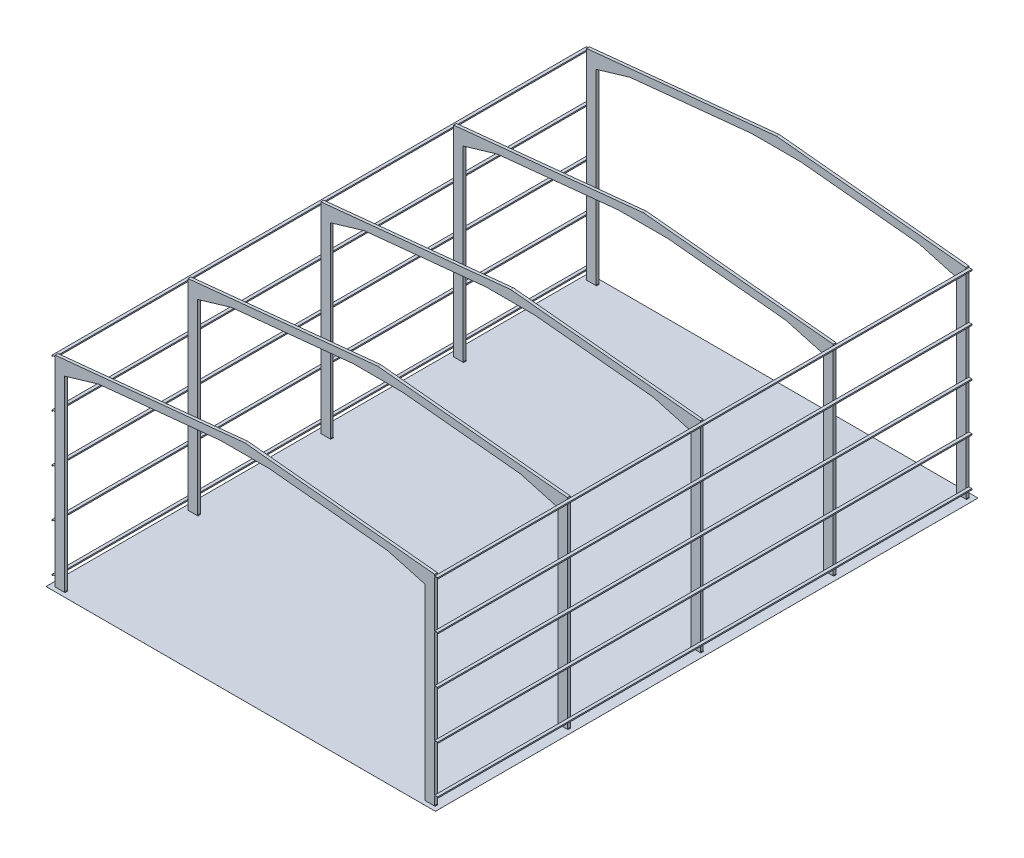
from build123d import *

# Parameters (mm, degrees)
EXTRUDE3_DEPTH       = 150
EXTRUDE4_DEPTH       = 28150
LPATTERN1_COUNT      = 5
LPATTERN1_PITCH      = 2500
MIRROR1_COPY_1_DEPTH = 28150
MIRROR1_COPY_2_DEPTH = 28150
MIRROR1_COPY_3_DEPTH = 28150
MIRROR1_COPY_4_DEPTH = 28150
LPATTERN2_COUNT      = 5
LPATTERN2_PITCH      = 7000
SKETCH57_W           = 20517.742297694
SKETCH57_H           = 28590
EXTRUDE5_DEPTH       = 1


with BuildPart() as part:
    # Sketch55 → Extrude3 (new body)
    with BuildSketch(Plane.XY):
        Polygon((128234.445628029, -90476.254441919), (128234.445628029, -80629.954441919), (130024.247115637, -80099.228646419), (136434.445628029, -79458.20879518), (137734.445628029, -79458.20879518), (139034.445628029, -79458.20879518), (145244.644140421, -80079.228646419), (147234.445628029, -80629.954441919), (147234.445628029, -90476.254441919), (147209.445628029, -90501.254441919), (147759.445628029, -90501.254441919), (147734.445628029, -90476.254441919), (147734.445628029, -79926.213770335), (137734.445628029, -78926.213770335), (127734.445628029, -79926.213770335), (127734.445628029, -90476.254441919), (127709.445628029, -90501.254441919), (128259.445628029, -90501.254441919), align=None)
    extrude3 = extrude(amount=EXTRUDE3_DEPTH)

    # Sketch56 → Extrude4 (add)
    with BuildSketch(Plane.XY):
        with BuildLine():
            Line((147891.623199959, -90066.254441919), (147894.445628029, -90066.254441919))
            Line((147894.445628029, -90066.254441919), (147894.445628029, -90001.254441919))
            Line((147894.445628029, -90001.254441919), (147734.445628029, -90001.254441919))
            Line((147734.445628029, -90001.254441919), (147734.445628029, -90066.254441919))
            Line((147734.445628029, -90066.254441919), (147737.268056099, -90066.254441919))
            ThreePointArc((147737.268056099, -90066.254441919), (147740.998854072, -90064.795623243), (147742.750540131, -90061.193040642))
            Line((147742.750540131, -90061.193040642), (147746.172614016, -90018.417117085))
            ThreePointArc((147746.172614016, -90018.417117085), (147749.516741947, -90011.539459393), (147756.63917444, -90008.754441919))
            Line((147756.63917444, -90008.754441919), (147814.445628029, -90008.754441919))
            Line((147814.445628029, -90008.754441919), (147872.252081618, -90008.754441919))
            ThreePointArc((147872.252081618, -90008.754441919), (147879.374514111, -90011.539459393), (147882.718642042, -90018.417117085))
            Line((147882.718642042, -90018.417117085), (147886.140715927, -90061.193040642))
            ThreePointArc((147886.140715927, -90061.193040642), (147887.892401986, -90064.795623243), (147891.623199959, -90066.254441919))
        make_face()
    extrude4 = extrude(amount=EXTRUDE4_DEPTH)

    # LPattern1: Extrude4 ×5
    with Locations(*[(0, i * LPATTERN1_PITCH, 0) for i in range(1, LPATTERN1_COUNT)]):
        add(extrude4)

    # Mirror1: Extrude4 across plane
    add(extrude4.mirror(Plane(origin=(137734.445628029, 0, 0), x_dir=(0, 0, 1), z_dir=(1, 0, 0))))

    # Mirror1 copy 1 sketch → Mirror1 copy 1 (add)
    with BuildSketch(Plane(origin=(275468.891256058, 2500, 0), x_dir=(-1, 0, 0), z_dir=(0, 0, 1))):
        with BuildLine():
            Line((147891.623199959, 90066.254441919), (147894.445628029, 90066.254441919))
            Line((147894.445628029, 90066.254441919), (147894.445628029, 90001.254441919))
            Line((147894.445628029, 90001.254441919), (147734.445628029, 90001.254441919))
            Line((147734.445628029, 90001.254441919), (147734.445628029, 90066.254441919))
            Line((147734.445628029, 90066.254441919), (147737.268056099, 90066.254441919))
            ThreePointArc((147737.268056099, 90066.254441919), (147740.998854072, 90064.795623243), (147742.750540131, 90061.193040642))
            Line((147742.750540131, 90061.193040642), (147746.172614016, 90018.417117085))
            ThreePointArc((147746.172614016, 90018.417117085), (147749.516741947, 90011.539459393), (147756.63917444, 90008.754441919))
            Line((147756.63917444, 90008.754441919), (147814.445628029, 90008.754441919))
            Line((147814.445628029, 90008.754441919), (147872.252081618, 90008.754441919))
            ThreePointArc((147872.252081618, 90008.754441919), (147879.374514111, 90011.539459393), (147882.718642042, 90018.417117085))
            Line((147882.718642042, 90018.417117085), (147886.140715927, 90061.193040642))
            ThreePointArc((147886.140715927, 90061.193040642), (147887.892401986, 90064.795623243), (147891.623199959, 90066.254441919))
        make_face()
    extrude(amount=MIRROR1_COPY_1_DEPTH)

    # Mirror1 copy 2 sketch → Mirror1 copy 2 (add)
    with BuildSketch(Plane(origin=(275468.891256058, 5000, 0), x_dir=(-1, 0, 0), z_dir=(0, 0, 1))):
        with BuildLine():
            Line((147891.623199959, 90066.254441919), (147894.445628029, 90066.254441919))
            Line((147894.445628029, 90066.254441919), (147894.445628029, 90001.254441919))
            Line((147894.445628029, 90001.254441919), (147734.445628029, 90001.254441919))
            Line((147734.445628029, 90001.254441919), (147734.445628029, 90066.254441919))
            Line((147734.445628029, 90066.254441919), (147737.268056099, 90066.254441919))
            ThreePointArc((147737.268056099, 90066.254441919), (147740.998854072, 90064.795623243), (147742.750540131, 90061.193040642))
            Line((147742.750540131, 90061.193040642), (147746.172614016, 90018.417117085))
            ThreePointArc((147746.172614016, 90018.417117085), (147749.516741947, 90011.539459393), (147756.63917444, 90008.754441919))
            Line((147756.63917444, 90008.754441919), (147814.445628029, 90008.754441919))
            Line((147814.445628029, 90008.754441919), (147872.252081618, 90008.754441919))
            ThreePointArc((147872.252081618, 90008.754441919), (147879.374514111, 90011.539459393), (147882.718642042, 90018.417117085))
            Line((147882.718642042, 90018.417117085), (147886.140715927, 90061.193040642))
            ThreePointArc((147886.140715927, 90061.193040642), (147887.892401986, 90064.795623243), (147891.623199959, 90066.254441919))
        make_face()
    extrude(amount=MIRROR1_COPY_2_DEPTH)

    # Mirror1 copy 3 sketch → Mirror1 copy 3 (add)
    with BuildSketch(Plane(origin=(275468.891256058, 7500, 0), x_dir=(-1, 0, 0), z_dir=(0, 0, 1))):
        with BuildLine():
            Line((147891.623199959, 90066.254441919), (147894.445628029, 90066.254441919))
            Line((147894.445628029, 90066.254441919), (147894.445628029, 90001.254441919))
            Line((147894.445628029, 90001.254441919), (147734.445628029, 90001.254441919))
            Line((147734.445628029, 90001.254441919), (147734.445628029, 90066.254441919))
            Line((147734.445628029, 90066.254441919), (147737.268056099, 90066.254441919))
            ThreePointArc((147737.268056099, 90066.254441919), (147740.998854072, 90064.795623243), (147742.750540131, 90061.193040642))
            Line((147742.750540131, 90061.193040642), (147746.172614016, 90018.417117085))
            ThreePointArc((147746.172614016, 90018.417117085), (147749.516741947, 90011.539459393), (147756.63917444, 90008.754441919))
            Line((147756.63917444, 90008.754441919), (147814.445628029, 90008.754441919))
            Line((147814.445628029, 90008.754441919), (147872.252081618, 90008.754441919))
            ThreePointArc((147872.252081618, 90008.754441919), (147879.374514111, 90011.539459393), (147882.718642042, 90018.417117085))
            Line((147882.718642042, 90018.417117085), (147886.140715927, 90061.193040642))
            ThreePointArc((147886.140715927, 90061.193040642), (147887.892401986, 90064.795623243), (147891.623199959, 90066.254441919))
        make_face()
    extrude(amount=MIRROR1_COPY_3_DEPTH)

    # Mirror1 copy 4 sketch → Mirror1 copy 4 (add)
    with BuildSketch(Plane(origin=(275468.891256058, 10000, 0), x_dir=(-1, 0, 0), z_dir=(0, 0, 1))):
        with BuildLine():
            Line((147891.623199959, 90066.254441919), (147894.445628029, 90066.254441919))
            Line((147894.445628029, 90066.254441919), (147894.445628029, 90001.254441919))
            Line((147894.445628029, 90001.254441919), (147734.445628029, 90001.254441919))
            Line((147734.445628029, 90001.254441919), (147734.445628029, 90066.254441919))
            Line((147734.445628029, 90066.254441919), (147737.268056099, 90066.254441919))
            ThreePointArc((147737.268056099, 90066.254441919), (147740.998854072, 90064.795623243), (147742.750540131, 90061.193040642))
            Line((147742.750540131, 90061.193040642), (147746.172614016, 90018.417117085))
            ThreePointArc((147746.172614016, 90018.417117085), (147749.516741947, 90011.539459393), (147756.63917444, 90008.754441919))
            Line((147756.63917444, 90008.754441919), (147814.445628029, 90008.754441919))
            Line((147814.445628029, 90008.754441919), (147872.252081618, 90008.754441919))
            ThreePointArc((147872.252081618, 90008.754441919), (147879.374514111, 90011.539459393), (147882.718642042, 90018.417117085))
            Line((147882.718642042, 90018.417117085), (147886.140715927, 90061.193040642))
            ThreePointArc((147886.140715927, 90061.193040642), (147887.892401986, 90064.795623243), (147891.623199959, 90066.254441919))
        make_face()
    extrude(amount=MIRROR1_COPY_4_DEPTH)

    # LPattern2: Extrude3 ×5
    with Locations(*[(0, 0, i * LPATTERN2_PITCH) for i in range(1, LPATTERN2_COUNT)]):
        add(extrude3)

    # Sketch57 → Extrude5 (add)
    with BuildSketch(Plane.XZ.offset(90501.254441919)):
        with Locations((137734.704573341, 14075)):
            Rectangle(SKETCH57_W, SKETCH57_H)
    extrude(amount=-EXTRUDE5_DEPTH)


solid = part.part
